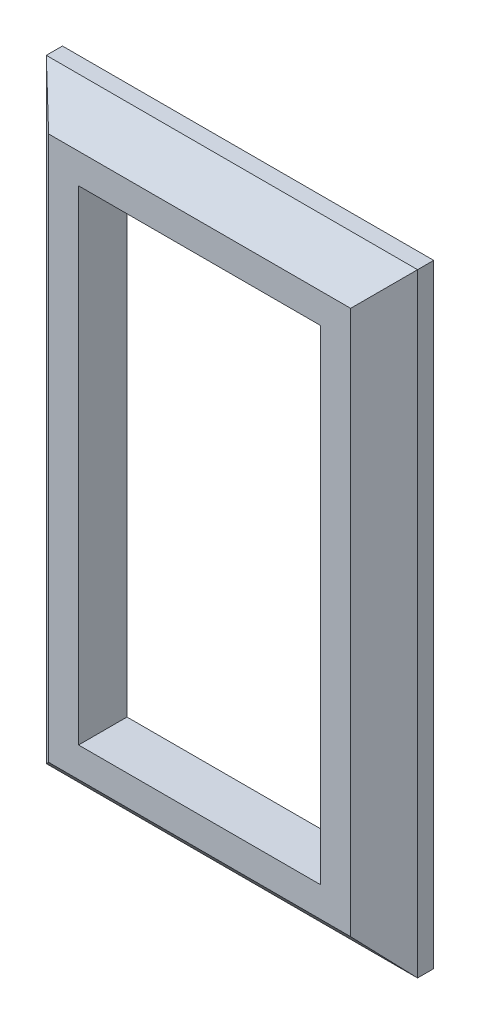
from build123d import *

# Parameters (mm, degrees)
ESBO_O1_W                = 23
ESBO_O1_H                = 38
ESBO_O1_W_2              = 15
ESBO_O1_H_2              = 30
RESSALTO_EXTRUS_O1_DEPTH = 3
CHANFRO1_SIZE            = 2
CHANFRO1_SIZE2           = 2.14473742
CHANFRO1_PART_2_SIZE     = 2
CHANFRO1_PART_2_SIZE2    = 2.14473742
CHANFRO1_PART_3_SIZE     = 2
CHANFRO1_PART_3_SIZE2    = 2.14473742
CHANFRO1_PART_4_SIZE     = 2
CHANFRO1_PART_4_SIZE2    = 2.14473742


with BuildPart() as part:
    # Esboço1 → Ressalto-extrusão1 (new body)
    with BuildSketch(Plane.XY):
        Rectangle(ESBO_O1_W, ESBO_O1_H)
        Rectangle(ESBO_O1_W_2, ESBO_O1_H_2, mode=Mode.SUBTRACT)
    extrude(amount=RESSALTO_EXTRUS_O1_DEPTH)

    # Chanfro1
    chanfro1_edges = [part.edges().sort_by_distance(p)[0] for p in [
        (11.5, 0, 3),
    ]]
    chanfro1_side = [part.faces().sort_by_distance(p)[0] for p in [
        (11.5, 0, 1.5),
    ]]
    chamfer(chanfro1_edges, length=CHANFRO1_SIZE, length2=CHANFRO1_SIZE2, reference=chanfro1_side[0])

    # Chanfro1 part 2
    chanfro1_part_2_edges = [part.edges().sort_by_distance(p)[0] for p in [
        (0, 19, 3),
    ]]
    chanfro1_part_2_side = [part.faces().sort_by_distance(p)[0] for p in [
        (0, 19, 1.5),
    ]]
    chamfer(chanfro1_part_2_edges, length=CHANFRO1_PART_2_SIZE, length2=CHANFRO1_PART_2_SIZE2, reference=chanfro1_part_2_side[0])

    # Chanfro1 part 3
    chanfro1_part_3_edges = [part.edges().sort_by_distance(p)[0] for p in [
        (-11.5, 0, 3),
    ]]
    chanfro1_part_3_side = [part.faces().sort_by_distance(p)[0] for p in [
        (-11.5, 0, 1.5),
    ]]
    chamfer(chanfro1_part_3_edges, length=CHANFRO1_PART_3_SIZE, length2=CHANFRO1_PART_3_SIZE2, reference=chanfro1_part_3_side[0])

    # Chanfro1 part 4
    chanfro1_part_4_edges = [part.edges().sort_by_distance(p)[0] for p in [
        (0, -19, 3),
    ]]
    chanfro1_part_4_side = [part.faces().sort_by_distance(p)[0] for p in [
        (0, -19, 1.5),
    ]]
    chamfer(chanfro1_part_4_edges, length=CHANFRO1_PART_4_SIZE, length2=CHANFRO1_PART_4_SIZE2, reference=chanfro1_part_4_side[0])


solid = part.part
